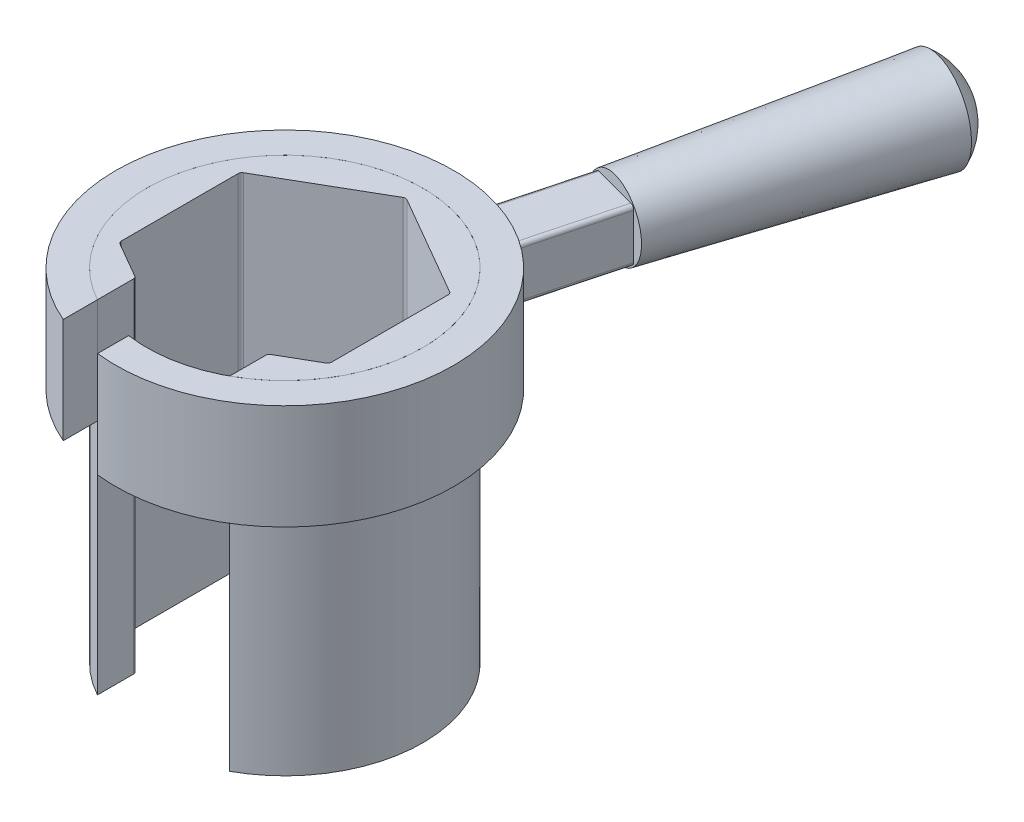
from build123d import *

# Parameters (mm, degrees)
EXTRUDE3_DEPTH                  = 44
EXTRUDE4_DEPTH                  = 13.5
SKETCH22_W                      = 6.8
SKETCH22_H                      = 6.8
EXTRUDE5_DEPTH                  = 13
EXTRUDE5_DIRECTION_2_REACH      = 69.1
EXTRUDE5_DIRECTION_2_END_RADIUS = 21.71
SKETCH23_R                      = 4.808326112
EXTRUDE6_DEPTH                  = 34
EXTRUDE6_DRAFT                  = -2
DOME1_FACE_RADIUS               = 5.995632275
DOME1_HEIGHT                    = 3
CUT_EXTRUDE7_DEPTH              = 86.573652668
FILLET2_R                       = 0.5
FILLET3_R                       = 0.5


with BuildPart() as part:
    # Sketch20 → Extrude3 (new body)
    with BuildSketch(Plane(origin=(0, 0, 0), x_dir=(1, 0, 0), z_dir=(0, 1, 0))):
        with BuildLine():
            Line((-8.5, -10.488088482), (-8.5, -15.582442042))
            ThreePointArc((-8.5, -15.582442042), (0, 17.75), (8.5, -15.582442042))
            Line((8.5, -15.582442042), (8.5, -10.488088482))
            ThreePointArc((8.5, -10.488088482), (0, 13.5), (-8.5, -10.488088482))
        make_face()
    extrude(amount=EXTRUDE3_DEPTH)

    # Sketch24 → Cut-Extrude7 (cut, through all)
    with BuildSketch(Plane.XZ):
        Polygon((-13.5, 7.794228634), (-13.5, -7.794228634), (0, -15.588457268), (13.5, -7.794228634), (13.5, 7.794228634), (0, 15.588457268), align=None)
    extrude(amount=-CUT_EXTRUDE7_DEPTH, mode=Mode.SUBTRACT)

    # Fillet3
    fillet3_edges = [part.edges().sort_by_distance(p)[0] for p in [
        (-8.5, 22, 10.68097998),
        (-13.5, 22, 7.794228634),
        (8.5, 22, 10.68097998),
        (13.5, 22, 7.794228634),
        (13.5, 22, -7.794228634),
        (0, 22, -15.588457268),
        (-13.5, 22, -7.794228634),
    ]]
    fillet(fillet3_edges, radius=FILLET3_R)


with BuildPart() as body_2:
    # Sketch21 → Extrude4 (new body)
    with BuildSketch(Plane(origin=(0, 43.999, 0), x_dir=(-1, 0, 0), z_dir=(0, 1, 0))):
        with BuildLine():
            Line((2.5, 17.573061771), (2.5, 21.565576737))
            ThreePointArc((2.5, 21.565576737), (-5.557069536, -20.986735767), (8.5, 19.976839089))
            Line((8.5, 19.976839089), (8.5, 15.582442042))
            ThreePointArc((8.5, 15.582442042), (-5.589332852, -16.847013334), (2.5, 17.573061771))
        make_face()
    extrude(amount=-EXTRUDE4_DEPTH)


with BuildPart() as body_3:
    # Sketch22 → Extrude5 (new body)
    with BuildSketch(Plane(origin=(5.557069536, 43.999, -20.986735767), x_dir=(-0.9666852034741763, 0, -0.2559681960402314), z_dir=(0.2559681960402314, 0, -0.9666852034741763))):
        with Locations((0, -6.75)):
            Rectangle(SKETCH22_W, SKETCH22_H)
    extrude(amount=EXTRUDE5_DEPTH)

    # Extrude5 direction 2: up to this cylinder (the profile starts outside it)
    extrude5_direction_2_end = Plane(origin=(0, 37.249, 0), z_dir=(0, 1, 0)) * Cylinder(EXTRUDE5_DIRECTION_2_END_RADIUS, 182.62, mode=Mode.PRIVATE)
    # Sketch22 → Extrude5 direction 2 (add, up to the surface)
    with BuildSketch(Plane(origin=(5.557069536, 43.999, -20.986735767), x_dir=(-0.9666852034741763, 0, -0.2559681960402314), z_dir=(0.2559681960402314, 0, -0.9666852034741763)), mode=Mode.PRIVATE) as extrude5_direction_2_sk1:
        with Locations((0, -6.75)):
            Rectangle(SKETCH22_W, SKETCH22_H)
    extrude5_direction_2_tool1 = extrude(extrude5_direction_2_sk1.sketch, amount=-EXTRUDE5_DIRECTION_2_REACH, mode=Mode.PRIVATE) - extrude5_direction_2_end
    add(extrude5_direction_2_tool1.solids().sort_by_distance((5.55707, 37.249, -20.986736))[0])
    add(extrude5_direction_2_tool1.solids().sort_by_distance((5.55707, 37.249, -20.986736))[1])


with BuildPart() as extrude6_tool:
    # Sketch23 → Extrude6 (with draft: the straight prism first)
    with BuildSketch(Plane(origin=(8.884656085, 0, -33.553643413), x_dir=(-0.9666852034741764, -1.6827536930173812e-15, -0.255968196040231), z_dir=(0.255968196040231, 0, -0.9666852034741764))):
        with Locations((0, 37.249)):
            Circle(SKETCH23_R)
    extrude(amount=EXTRUDE6_DEPTH)
    # Extrude6: the draft: its side faces are tilted about the plane it starts from
    extrude6_sides = [extrude6_tool.faces().sort_by_distance(p)[0] for p in [
        (17.884253123, 37.249, -48.756513311),
    ]]
    draft(extrude6_sides, Plane(origin=(8.884656085, 0, -33.553643413), x_dir=(-0.9666852034741764, -1.6827536930173812e-15, -0.255968196040231), z_dir=(0.255968196040231, 0, -0.9666852034741764)), EXTRUDE6_DRAFT)


with BuildPart() as body_3_1:
    add(body_3.part)

    # Extrude6: add extrude6_tool
    add(extrude6_tool.part)

    # Dome1: a dome of height H over a round flat face of radius A is a cap of a sphere of radius (A * A + H * H) / (2 * H)
    dome1_r = (DOME1_FACE_RADIUS * DOME1_FACE_RADIUS + DOME1_HEIGHT * DOME1_HEIGHT) / (2 * DOME1_HEIGHT)
    dome1_base = Plane((17.58757475, 37.249, -66.420940331), z_dir=(0.25596819604, 0, -0.966685203474))
    with Locations(dome1_base.offset(DOME1_HEIGHT - dome1_r)):
        dome1_ball = Sphere(dome1_r, mode=Mode.PRIVATE)
    add(split(dome1_ball, bisect_by=dome1_base, keep=Keep.TOP, mode=Mode.PRIVATE))

    # Fillet2
    fillet2_edges = [body_3_1.edges().sort_by_distance(p)[0] for p in [
        (10.473306898, 40.649, -26.270415285),
        (3.899847514, 40.649, -28.010999018),
        (3.899847514, 33.849, -28.010999018),
        (10.473306898, 33.849, -26.270415285),
    ]]
    fillet(fillet2_edges, radius=FILLET2_R)


solid = Compound([part.part, body_2.part, body_3_1.part])
